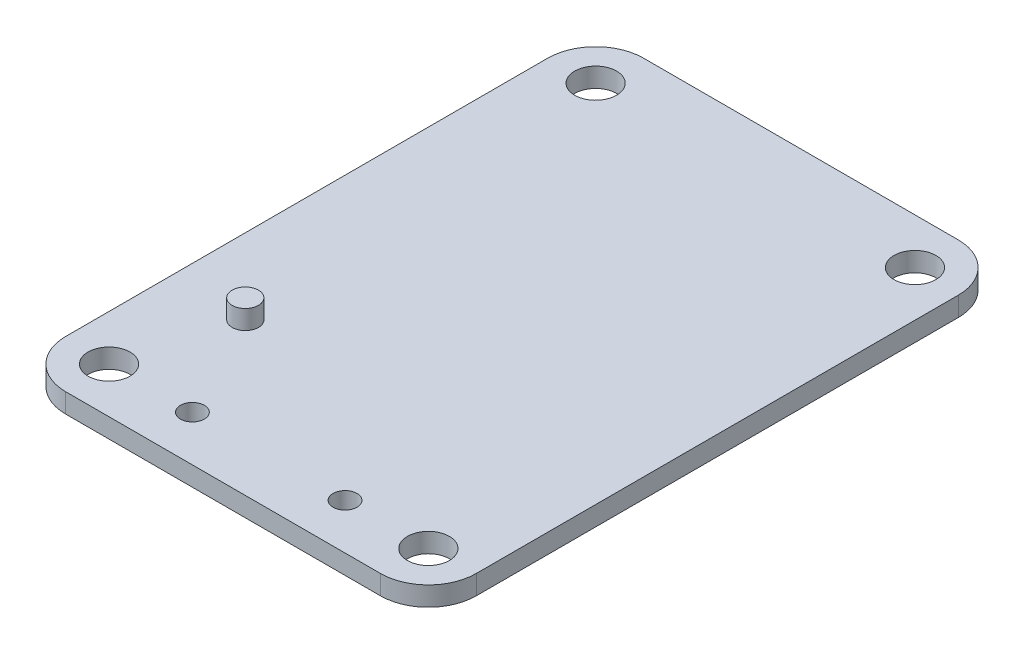
from build123d import *

# Parameters (mm, degrees)
SKETCH1_R           = 1.75
BOSS_EXTRUDE1_DEPTH = 1.62
SKETCH2_R           = 1
CUT_EXTRUDE1_DEPTH  = 1.62
SKETCH3_R           = 1.1
BOSS_EXTRUDE2_DEPTH = 1.6


with BuildPart() as part:
    # Sketch1 → Boss-Extrude1 (new body)
    with BuildSketch(Plane(origin=(0, 0, 0), x_dir=(1, 0, 0), z_dir=(0, 1, 0))):
        with BuildLine():
            Line((30.29, 48.26), (4, 48.26))
            ThreePointArc((4, 48.26), (1.171572875, 47.088427125), (0, 44.26))
            Line((0, 44.26), (0, 4))
            ThreePointArc((0, 4), (1.171572875, 1.171572875), (4, 0))
            Line((4, 0), (30.29, 0))
            ThreePointArc((30.29, 0), (33.118427125, 1.171572875), (34.29, 4))
            Line((34.29, 4), (34.29, 44.26))
            ThreePointArc((34.29, 44.26), (33.118427125, 47.088427125), (30.29, 48.26))
        make_face()
        with Locations((30.48, 44.45)):
            Circle(SKETCH1_R, mode=Mode.SUBTRACT)
        with Locations((3.81, 44.45)):
            Circle(SKETCH1_R, mode=Mode.SUBTRACT)
        with Locations((30.48, 3.81)):
            Circle(SKETCH1_R, mode=Mode.SUBTRACT)
        with Locations((3.81, 3.81)):
            Circle(SKETCH1_R, mode=Mode.SUBTRACT)
    extrude(amount=BOSS_EXTRUDE1_DEPTH)

    # Sketch2 → Cut-Extrude1 (cut)
    with BuildSketch(Plane(origin=(0, 1.62, 0), x_dir=(1, 0, 0), z_dir=(0, 1, 0))):
        with Locations((23.52, 3.81)):
            Circle(SKETCH2_R)
        with Locations((10.77, 3.81)):
            Circle(SKETCH2_R)
    extrude(amount=-CUT_EXTRUDE1_DEPTH, mode=Mode.SUBTRACT)

    # Sketch3 → Boss-Extrude2 (add)
    with BuildSketch(Plane(origin=(0, 1.62, 0), x_dir=(1, 0, 0), z_dir=(0, 1, 0))):
        with Locations((6.3, 12.7)):
            Circle(SKETCH3_R)
    extrude(amount=BOSS_EXTRUDE2_DEPTH)


solid = part.part
